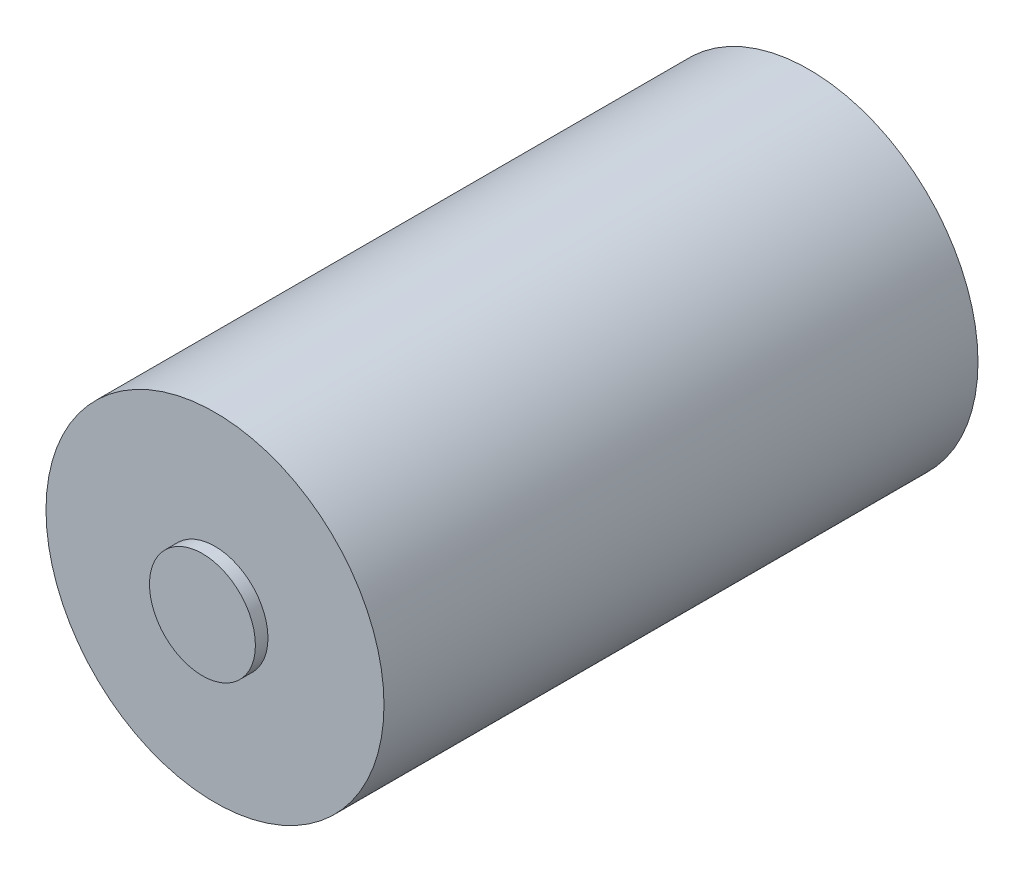
from build123d import *

# Parameters (mm, degrees)
SKETCH1_R           = 6.33
BOSS_EXTRUDE1_DEPTH = 1.5
SKETCH2_R           = 20.2
BOSS_EXTRUDE2_DEPTH = 71
SKETCH6_R           = 6
BOSS_EXTRUDE4_DEPTH = 3
SKETCH7_R           = 2
BOSS_EXTRUDE5_DEPTH = 9
SKETCH8_R           = 1.65
CUT_EXTRUDE1_DEPTH  = 4


with BuildPart() as part:
    # Sketch1 → Boss-Extrude1 (new body)
    with BuildSketch(Plane.XY):
        Circle(SKETCH1_R)
    extrude(amount=BOSS_EXTRUDE1_DEPTH)

    # Sketch2 → Boss-Extrude2 (add)
    with BuildSketch(Plane.XY):
        Circle(SKETCH2_R)
    extrude(amount=-BOSS_EXTRUDE2_DEPTH)

    # Sketch6 → Boss-Extrude4 (add)
    with BuildSketch(Plane(origin=(0, 0, -71), x_dir=(-1, 0, 0), z_dir=(0, 0, -1))):
        Circle(SKETCH6_R)
    extrude(amount=BOSS_EXTRUDE4_DEPTH)

    # Sketch7 → Boss-Extrude5 (add)
    with BuildSketch(Plane(origin=(0, 0, -74), x_dir=(-1, 0, 0), z_dir=(0, 0, -1))):
        Circle(SKETCH7_R)
    extrude(amount=BOSS_EXTRUDE5_DEPTH)

    # Sketch8 → Cut-Extrude1 (cut)
    with BuildSketch(Plane(origin=(0, 0, -71), x_dir=(-1, 0, 0), z_dir=(0, 0, -1))):
        with Locations((-12.5, 0)):
            Circle(SKETCH8_R)
        with Locations((12.5, 0)):
            Circle(SKETCH8_R)
    extrude(amount=-CUT_EXTRUDE1_DEPTH, mode=Mode.SUBTRACT)


solid = part.part
